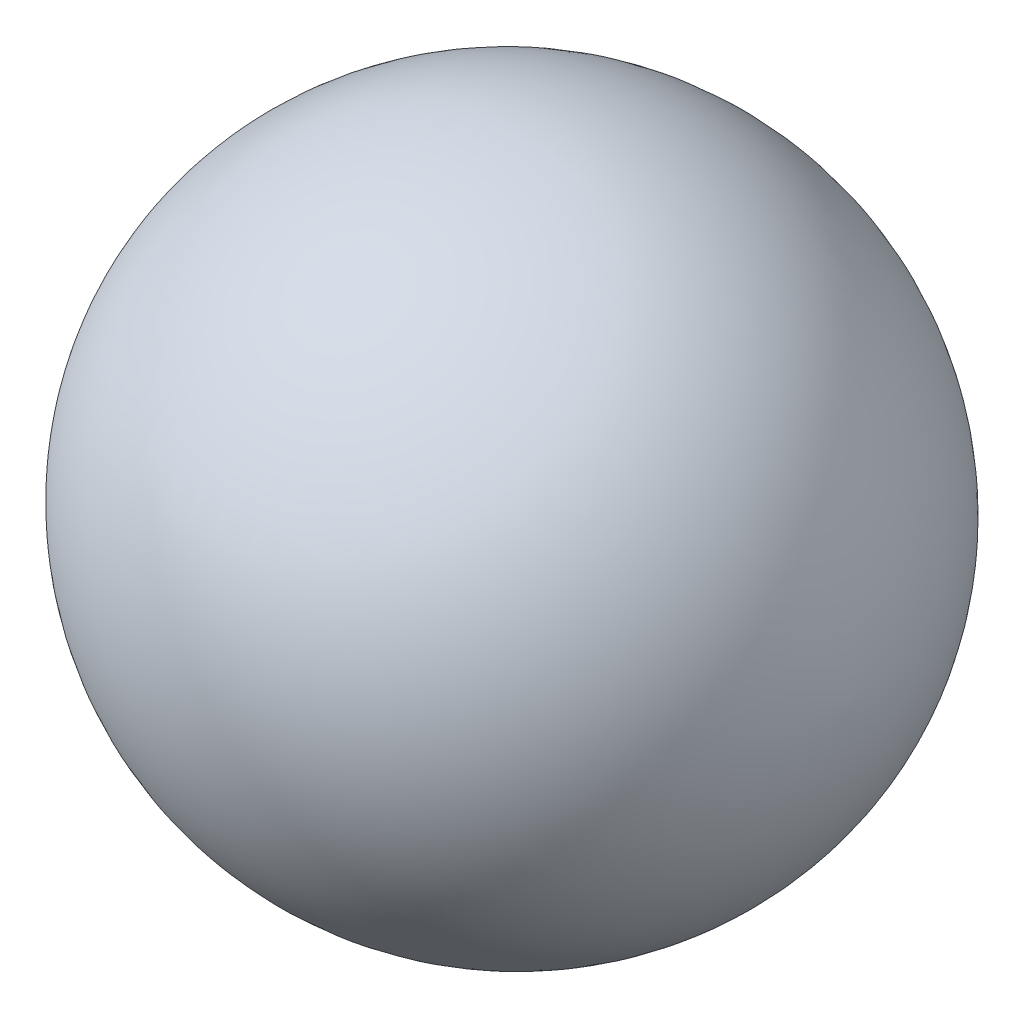
from build123d import *


with BuildPart() as part:
    # Sketch1 → Revolve1 (revolve)
    with BuildSketch(Plane(origin=(0, 0, 0), x_dir=(1, 0, 0), z_dir=(0, 1, 0))):
        with BuildLine():
            Line((-304.8, 0), (304.8, 0))
            ThreePointArc((304.8, 0), (0, -293.88099333), (-304.8, 0))
        make_face()
    revolve(axis=Axis((-304.8, 0, 0), (1, 0, 0)))


solid = part.part
